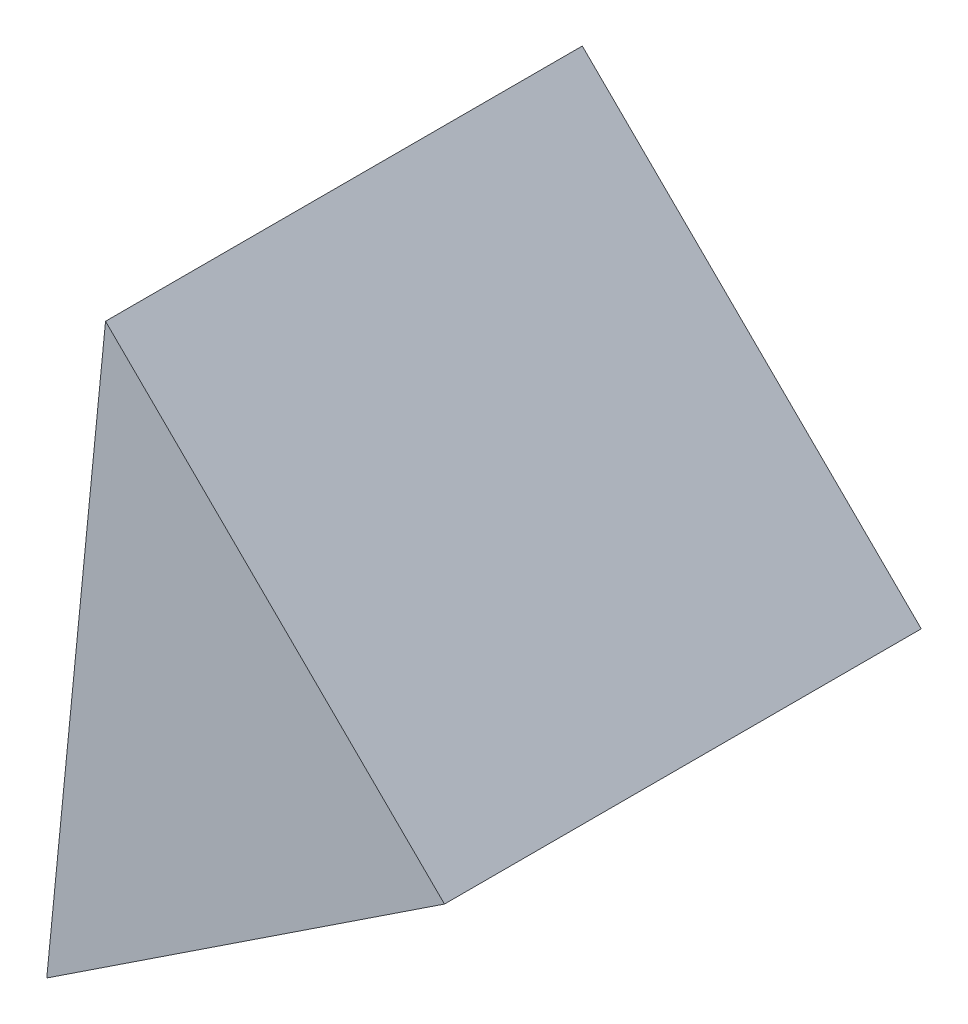
from build123d import *

# Parameters (mm, degrees)
EXTRUDE_1_DEPTH = 15


with BuildPart() as part:
    # 草图2 → 凸台-拉伸1 (new body)
    with BuildSketch(Plane.XY):
        Polygon((13.19977079, 9.118493995), (2.535178436, 19.66678627), (0.686170974, 0.847471105), align=None)
    extrude(amount=EXTRUDE_1_DEPTH)


solid = part.part
